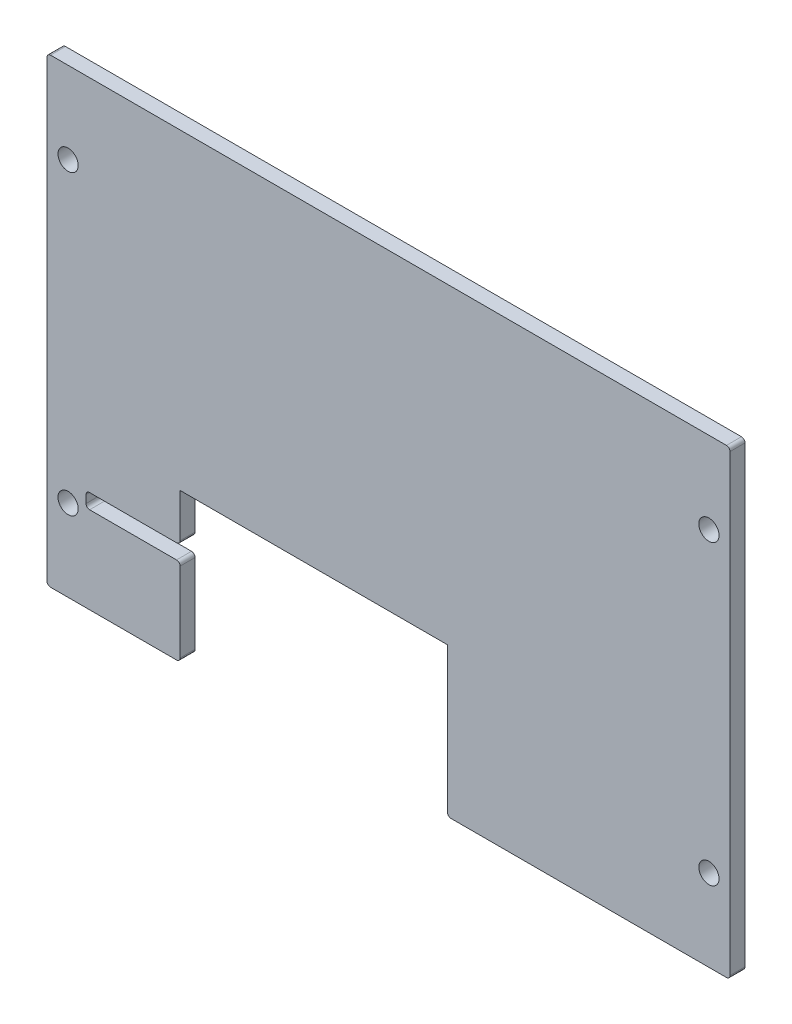
from build123d import *

# Parameters (mm, degrees)
SKETCH1_W           = 145.885353282
SKETCH1_H           = 98.425
BOSS_EXTRUDE1_DEPTH = 3.2004
SKETCH4_W           = 57.100000132
SKETCH4_H           = 31.75
CUT_EXTRUDE1_DEPTH  = 3.2004
SKETCH5_R           = 2.159
CUT_EXTRUDE2_DEPTH  = 3.2004
SKETCH7_W           = 20.092850022
SKETCH7_H           = 3.175
CUT_EXTRUDE4_DEPTH  = 3.2004
FILLET1_R           = 0.762


with BuildPart() as part:
    # Sketch1 → Boss-Extrude1 (new body)
    with BuildSketch(Plane.XY):
        with Locations((72.942676641, 49.2125)):
            Rectangle(SKETCH1_W, SKETCH1_H)
    extrude(amount=BOSS_EXTRUDE1_DEPTH)

    # Sketch4 → Cut-Extrude1 (cut)
    with BuildSketch(Plane.XY.offset(3.2004)):
        with Locations((56.982760066, 15.875)):
            Rectangle(SKETCH4_W, SKETCH4_H)
    extrude(amount=-CUT_EXTRUDE1_DEPTH, mode=Mode.SUBTRACT)

    # Sketch5 → Cut-Extrude2 (cut)
    with BuildSketch(Plane.XY.offset(3.2004)):
        with Locations((141.376853282, 80.9625)):
            Circle(SKETCH5_R)
        with Locations((141.376853282, 17.4625)):
            Circle(SKETCH5_R)
        with Locations((4.5085, 17.4625)):
            Circle(SKETCH5_R)
        with Locations((4.5085, 80.9625)):
            Circle(SKETCH5_R)
    extrude(amount=-CUT_EXTRUDE2_DEPTH, mode=Mode.SUBTRACT)

    # Sketch7 → Cut-Extrude4 (cut)
    with BuildSketch(Plane(origin=(0, 0, 0), x_dir=(-1, 0, 0), z_dir=(0, 0, -1))):
        with Locations((-18.386334989, 20.09902)):
            Rectangle(SKETCH7_W, SKETCH7_H)
    extrude(amount=-CUT_EXTRUDE4_DEPTH, mode=Mode.SUBTRACT)

    # Fillet1
    fillet1_edges = [part.edges().sort_by_distance(p)[0] for p in [
        (28.43276, 0, 1.6002),
        (85.532760132, 0, 1.6002),
        (8.339909978, 18.51152, 1.6002),
        (8.339909978, 21.68652, 1.6002),
        (28.43276, 21.68652, 1.6002),
        (28.43276, 18.51152, 1.6002),
        (0, 98.425, 1.6002),
        (145.885353282, 98.425, 1.6002),
        (145.885353282, 0, 1.6002),
        (0, 0, 1.6002),
    ]]
    fillet(fillet1_edges, radius=FILLET1_R)


solid = part.part
